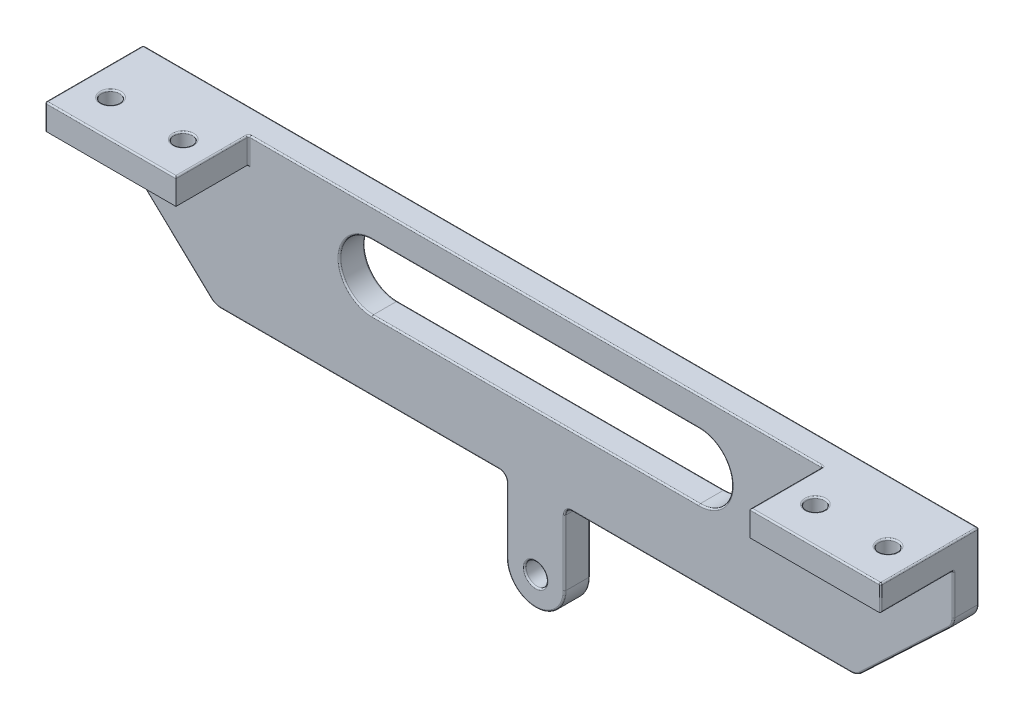
from build123d import *

# Parameters (mm, degrees)
SKETCH5_R           = 1.5
BOSS_EXTRUDE1_DEPTH = 3.5
SKETCH6_W           = 18
SKETCH6_H           = 10
SKETCH6_R           = 1.25
BOSS_EXTRUDE2_DEPTH = 3.5
FILLET1_R           = 2
FILLET2_R           = 1
FILLET3_R           = 0.2


with BuildPart() as part:
    # Sketch5 → Boss-Extrude1 (new body)
    with BuildSketch(Plane.XY):
        with BuildLine():
            Line((57.5, 92.615403731), (-57.5, 92.615403731))
            Line((-57.5, 92.615403731), (-57.5, 82.615403731))
            Line((-57.5, 82.615403731), (-44.142135624, 70))
            Line((-44.142135624, 70), (-4, 70))
            Line((-4, 70), (-4, 60))
            ThreePointArc((-4, 60), (0, 56), (4, 60))
            Line((4, 60), (4, 70))
            Line((4, 70), (44.142135624, 70))
            Line((44.142135624, 70), (57.5, 82.615403731))
            Line((57.5, 82.615403731), (57.5, 92.615403731))
        make_face()
        with Locations((0, 60)):
            Circle(SKETCH5_R, mode=Mode.SUBTRACT)
        with BuildLine():
            Line((22.5, 88.615403731), (-22.5, 88.615403731))
            ThreePointArc((-22.5, 88.615403731), (-27, 84.115403731), (-22.5, 79.615403731))
            Line((-22.5, 79.615403731), (22.5, 79.615403731))
            ThreePointArc((22.5, 79.615403731), (27, 84.115403731), (22.5, 88.615403731))
        make_face(mode=Mode.SUBTRACT)
    extrude(amount=BOSS_EXTRUDE1_DEPTH)

    # Sketch6 → Boss-Extrude2 (add)
    with BuildSketch(Plane(origin=(0, 92.615403731, 0), x_dir=(1, 0, 0), z_dir=(0, 1, 0))):
        with Locations((48.5, -8.5)):
            Rectangle(SKETCH6_W, SKETCH6_H)
        with Locations((53.5, -8.5)):
            Circle(SKETCH6_R, mode=Mode.SUBTRACT)
        with Locations((43.5, -8.5)):
            Circle(SKETCH6_R, mode=Mode.SUBTRACT)
        with Locations((-48.5, -8.5)):
            Rectangle(SKETCH6_W, SKETCH6_H)
        with Locations((-43.5, -8.5)):
            Circle(SKETCH6_R, mode=Mode.SUBTRACT)
        with Locations((-53.5, -8.5)):
            Circle(SKETCH6_R, mode=Mode.SUBTRACT)
    extrude(amount=-BOSS_EXTRUDE2_DEPTH)

    # Fillet1
    fillet1_edges = [part.edges().sort_by_distance(p)[0] for p in [
        (57.5, 82.615403731, 1.75),
        (44.142135624, 70, 1.75),
        (-44.142135624, 70, 1.75),
        (-57.5, 82.615403731, 1.75),
    ]]
    fillet(fillet1_edges, radius=FILLET1_R)

    # Fillet2
    fillet2_edges = [part.edges().sort_by_distance(p)[0] for p in [
        (4, 70, 1.75),
        (-4, 70, 1.75),
    ]]
    fillet(fillet2_edges, radius=FILLET2_R)

    # Fillet3
    fillet3_edges = [part.edges().sort_by_distance(p)[0] for p in [
        (0, 92.615403731, 0),
        (24.173497357, 70, 0),
        (24.173497357, 70, 3.5),
        (-4, 64.5, 0),
        (-4, 64.5, 3.5),
        (4.292893219, 69.707106781, 0),
        (4.292893219, 69.707106781, 3.5),
        (-4.292893219, 69.707106781, 0),
        (-4.292893219, 69.707106781, 3.5),
        (4, 64.5, 0),
        (0, 56, 0),
        (-57.5, 88.046458597, 0),
        (-57.5, 92.615403731, 6.75),
        (57.5, 92.615403731, 6.75),
        (0, 56, 3.5),
        (4, 64.5, 3.5),
        (-27, 84.115403731, 0),
        (0, 79.615403731, 0),
        (27, 84.115403731, 0),
        (0, 88.615403731, 0),
        (-27, 84.115403731, 3.5),
        (0, 79.615403731, 3.5),
        (27, 84.115403731, 3.5),
        (0, 88.615403731, 3.5),
        (-1.5, 60, 0),
        (-1.5, 60, 3.5),
        (0, 92.615403731, 3.5),
        (48.5, 89.115403731, 3.5),
        (39.5, 90.865403731, 3.5),
        (57.5, 89.115403731, 8.5),
        (57.5, 90.865403731, 13.5),
        (39.5, 92.615403731, 8.5),
        (48.5, 92.615403731, 13.5),
        (52.25, 92.615403731, 8.5),
        (42.25, 92.615403731, 8.5),
        (-57.5, 86.296458597, 3.5),
        (-39.5, 90.865403731, 3.5),
        (-57.5, 89.115403731, 8.5),
        (-57.5, 90.865403731, 13.5),
        (-48.5, 89.115403731, 3.5),
        (-39.5, 92.615403731, 8.5),
        (-48.5, 92.615403731, 13.5),
        (-44.75, 92.615403731, 8.5),
        (-54.75, 92.615403731, 8.5),
        (-24.173497357, 70, 0),
        (-24.173497357, 70, 3.5),
        (57.5, 88.046458597, 0),
        (50.796723879, 76.284711024, 0),
        (-50.796723879, 76.284711024, 0),
        (57.336634564, 82.685823197, 0),
        (44.085881913, 70.141493689, 0),
        (-57.336634564, 82.685823197, 0),
        (-44.085881913, 70.141493689, 0),
        (-50.796723879, 76.284711024, 3.5),
        (50.796723879, 76.284711024, 3.5),
        (57.5, 86.296458597, 3.5),
        (57.336634564, 82.685823197, 3.5),
        (44.085881913, 70.141493689, 3.5),
        (-57.336634564, 82.685823197, 3.5),
        (-44.085881913, 70.141493689, 3.5),
    ]]
    fillet(fillet3_edges, radius=FILLET3_R)


solid = part.part
